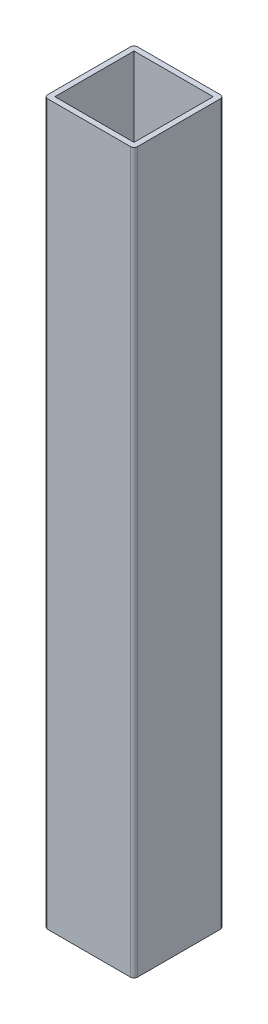
from build123d import *

# Parameters (mm, degrees)
SKETCH1_W           = 44
SKETCH1_H           = 44
BOSS_EXTRUDE1_DEPTH = 400


with BuildPart() as part:
    # Sketch1 → Boss-Extrude1 (new body)
    with BuildSketch(Plane(origin=(0, 0, 0), x_dir=(1, 0, 0), z_dir=(0, 1, 0))):
        with BuildLine():
            Line((2, 0), (48, 0))
            ThreePointArc((48, 0), (49.414213562, 0.585786438), (50, 2))
            Line((50, 2), (50, 48))
            ThreePointArc((50, 48), (49.414213562, 49.414213562), (48, 50))
            Line((48, 50), (2, 50))
            ThreePointArc((2, 50), (0.585786438, 49.414213562), (0, 48))
            Line((0, 48), (0, 2))
            ThreePointArc((0, 2), (0.585786438, 0.585786438), (2, 0))
        make_face()
        with Locations((25, 25)):
            Rectangle(SKETCH1_W, SKETCH1_H, mode=Mode.SUBTRACT)
    extrude(amount=BOSS_EXTRUDE1_DEPTH)


solid = part.part
